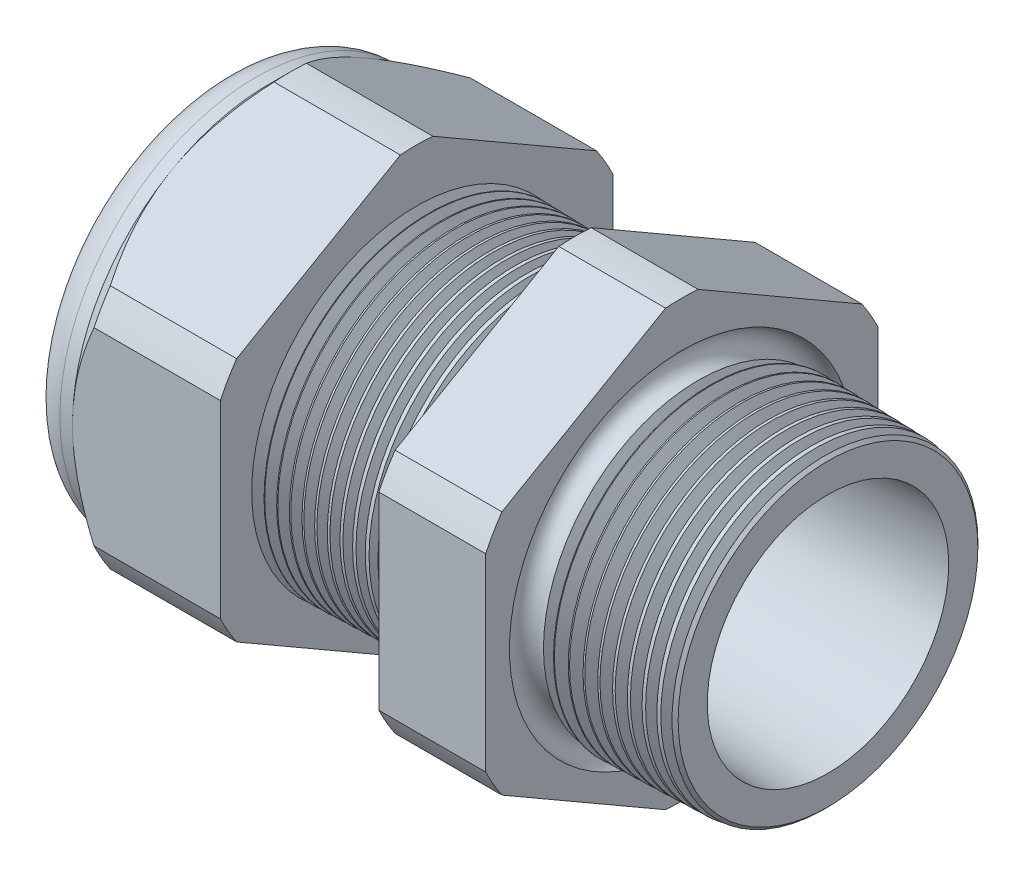
from build123d import *

# Parameters (mm, degrees)
SKETCH12_OUTSIDE_W = 65.136
SKETCH12_OUTSIDE_H = 65.136
CUT_EXTRUDE2_DEPTH = 35.03
FILLET4_R          = 2.032
SKETCH19_OUTSIDE_W = 40.13
SKETCH19_OUTSIDE_H = 42.756
SKETCH19_OUTSIDE_R = 11.938
CUT_EXTRUDE3_DEPTH = 1.999996
CUT_EXTRUDE3_DRAFT = -45
CHAMFER1_SIZE      = 0.260919487
CHAMFER1_SIZE2     = 0.254
SKETCH21_R         = 5.969
PLUG_DEPTH         = 6.35
SKETCH22_R         = 5.715
CUT_EXTRUDE4_DEPTH = 0.508
SKETCH27_R         = 2.54
PLUGHOLES_DEPTH    = 37.322
CIRPATTERN1_COUNT  = 2
LPATTERN1_COUNT    = 13
LPATTERN1_PITCH    = 0.762
LPATTERN2_COUNT    = 10
LPATTERN2_PITCH    = 0.889
SKETCH32_R         = 0.889


with BuildPart() as part:
    # Sketch10 → Revolve2 (revolve)
    with BuildSketch(Plane.XY, mode=Mode.PRIVATE) as revolve2_sk:
        Polygon((-35.814, 5.969), (-24.014, 5.969), (1.016, 7.345566383), (1.016, 9.377566383), (-7.874, 9.610359226), (-7.874, 23.876), (-14.374, 23.876), (-14.374, 9.780567716), (-24.014, 10.033), (-24.014, 23.876), (-33.014, 23.876), (-33.014, 11.938), (-35.814, 11.938), align=None)
    revolve(revolve2_sk.sketch.rotate(Axis((0, 0, 0), (-1, 0, 0)), 90), axis=Axis((0, 0, 0), (-1, 0, 0)))  # turned: the seam where the file's is

    # Sketch12 outside → Cut-Extrude2 (cut, through all)
    with BuildSketch(Plane.ZY.offset(33.014)):
        Rectangle(SKETCH12_OUTSIDE_W, SKETCH12_OUTSIDE_H)
        with BuildLine():
            Line((-0.98819228, 13.214281948), (-10.94980772, 7.462940592))
            ThreePointArc((-10.94980772, 7.462940592), (-11.47585851, 6.62559), (-11.938, 5.751341356))
            Line((-11.938, 5.751341356), (-11.938, -5.751341356))
            ThreePointArc((-11.938, -5.751341356), (-11.47585851, -6.62559), (-10.94980772, -7.462940592))
            Line((-10.94980772, -7.462940592), (-0.98819228, -13.214281948))
            ThreePointArc((-0.98819228, -13.214281948), (0, -13.25118), (0.98819228, -13.214281948))
            Line((0.98819228, -13.214281948), (10.94980772, -7.462940592))
            ThreePointArc((10.94980772, -7.462940592), (11.47585851, -6.62559), (11.938, -5.751341356))
            Line((11.938, -5.751341356), (11.938, 5.751341356))
            ThreePointArc((11.938, 5.751341356), (11.47585851, 6.62559), (10.94980772, 7.462940592))
            Line((10.94980772, 7.462940592), (0.98819228, 13.214281948))
            ThreePointArc((0.98819228, 13.214281948), (0, 13.25118), (-0.98819228, 13.214281948))
        make_face(mode=Mode.SUBTRACT)
    extrude(amount=-CUT_EXTRUDE2_DEPTH, mode=Mode.SUBTRACT)

    # Fillet4
    fillet4_edges = [part.edges().sort_by_distance(p)[0] for p in [
        (-35.814, 0, 11.938),
    ]]
    fillet(fillet4_edges, radius=FILLET4_R)


with BuildPart() as cut_extrude3_tool:
    # Sketch19 outside → Cut-Extrude3 (with draft: the straight prism first)
    with BuildSketch(Plane.ZY.offset(33.014)):
        Rectangle(SKETCH19_OUTSIDE_W, SKETCH19_OUTSIDE_H)
        Circle(SKETCH19_OUTSIDE_R, mode=Mode.SUBTRACT)
    extrude(amount=-CUT_EXTRUDE3_DEPTH)
    # Cut-Extrude3: the draft: its side faces are tilted about the plane it starts from
    cut_extrude3_sides = [cut_extrude3_tool.faces().sort_by_distance(p)[0] for p in [
        (-32.014002, -21.378, 0),
        (-32.014002, 0, 20.065),
        (-32.014002, 21.378, 0),
        (-32.014002, 0, -20.065),
        (-32.014002, 0, -11.938),
    ]]
    draft(cut_extrude3_sides, Plane.ZY.offset(33.014), CUT_EXTRUDE3_DRAFT)


with BuildPart() as part_1:
    add(part.part)

    # Cut-Extrude3: cut by cut_extrude3_tool
    add(cut_extrude3_tool.part, mode=Mode.SUBTRACT)

    # Chamfer1
    chamfer1_edges = [part_1.edges().sort_by_distance(p)[0] for p in [
        (1.016, 0, 9.377566383),
    ]]
    chamfer1_side = [part_1.faces().sort_by_distance(p)[0] for p in [
        (1.016, 0, 7.610804014),
    ]]
    chamfer(chamfer1_edges, length=CHAMFER1_SIZE, length2=CHAMFER1_SIZE2, reference=chamfer1_side[0])

    # Sketch29 → Cut-Revolve1 (revolve, cut)
    with BuildSketch(Plane.XY, mode=Mode.PRIVATE) as cut_revolve1_sk:
        Polygon((-24.014, 10.033), (-23.281016419, 10.013806149), (-23.664130572, 9.388620673), align=None)
    cut_revolve1 = revolve(cut_revolve1_sk.sketch.rotate(Axis((0, 0, 0), (-1, 0, 0)), 90), axis=Axis((0, 0, 0), (-1, 0, 0)), mode=Mode.SUBTRACT)  # turned: the seam where the file's is

    # LPattern1: Cut-Revolve1 ×13
    with Locations(*[(i * LPATTERN1_PITCH, 0, 0) for i in range(1, LPATTERN1_COUNT)]):
        add(cut_revolve1, mode=Mode.SUBTRACT)

    # Sketch30 → Cut-Revolve2 (revolve, cut)
    with BuildSketch(Plane.XY, mode=Mode.PRIVATE) as cut_revolve2_sk:
        Polygon((-7.874, 9.610359226), (-6.994419703, 9.587326605), (-7.454156686, 8.837104034), align=None)
    cut_revolve2 = revolve(cut_revolve2_sk.sketch.rotate(Axis((0, 0, 0), (-1, 0, 0)), 270), axis=Axis((0, 0, 0), (-1, 0, 0)), mode=Mode.SUBTRACT)  # turned: the seam where the file's is

    # LPattern2: Cut-Revolve2 ×10
    with Locations(*[(i * LPATTERN2_PITCH, 0, 0) for i in range(1, LPATTERN2_COUNT)]):
        add(cut_revolve2, mode=Mode.SUBTRACT)

    # Sketch32 → Cut-Revolve3 (revolve, cut)
    with BuildSketch(Plane.XY, mode=Mode.PRIVATE) as cut_revolve3_sk:
        with Locations((-7.747, 9.610359226)):
            Circle(SKETCH32_R)
    revolve(cut_revolve3_sk.sketch.rotate(Axis((0, 0, 0), (-1, 0, 0)), 270), axis=Axis((0, 0, 0), (-1, 0, 0)), mode=Mode.SUBTRACT)  # turned: the seam where the file's is


with BuildPart() as body_2:
    # Sketch21 → plug (new body)
    with BuildSketch(Plane.ZY.offset(35.814)):
        Circle(SKETCH21_R)
    extrude(amount=-PLUG_DEPTH)

    # Sketch22 → Cut-Extrude4 (cut)
    with BuildSketch(Plane.ZY.offset(35.814)):
        Circle(SKETCH22_R)
    extrude(amount=-CUT_EXTRUDE4_DEPTH, mode=Mode.SUBTRACT)

    # Sketch27 → plugholes (cut, through all)
    with BuildSketch(Plane.ZY.offset(35.306)):
        with Locations((-3.16484, 0)):
            Circle(SKETCH27_R)
    plugholes = extrude(amount=-PLUGHOLES_DEPTH, mode=Mode.SUBTRACT)

    # CirPattern1: plugholes ×2 about axis
    cirpattern1_axis = Axis((0, 0, 0), (1, 0, 0))
    for i in range(1, CIRPATTERN1_COUNT):
        add(plugholes.rotate(cirpattern1_axis, i * 360 / CIRPATTERN1_COUNT), mode=Mode.SUBTRACT)


solid = Compound([part_1.part, body_2.part])
